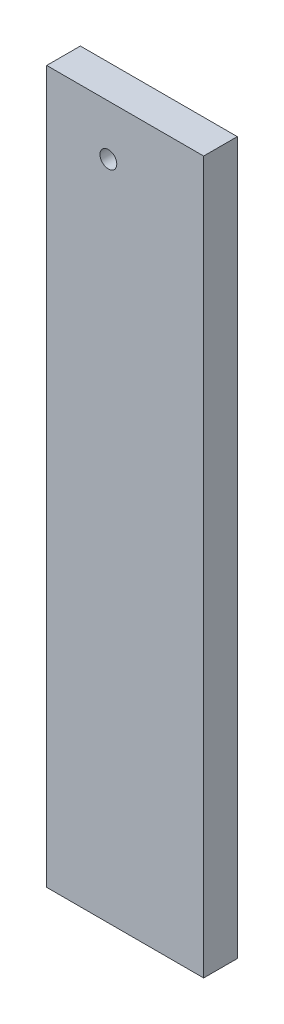
from build123d import *

# Parameters (mm, degrees)
SKETCH1_W               = 88.9
SKETCH1_H               = 403.225
BOSS_EXTRUDE1_DEPTH     = 9.525
SKETCH2_R               = 4.7625
CUT_EXTRUDE1_DEPTH      = 1
CUT_EXTRUDE1_DEPTH_BACK = 20.05


with BuildPart() as part:
    # Sketch1 → Boss-Extrude1 (new body, symmetric)
    with BuildSketch(Plane.XY):
        Rectangle(SKETCH1_W, SKETCH1_H)
    extrude(amount=BOSS_EXTRUDE1_DEPTH, both=True)

    # Sketch2 → Cut-Extrude1 (cut, two sides)
    with BuildSketch(Plane.XY.offset(9.525)) as cut_extrude1_sk:
        with Locations((-9.525, 173.0375)):
            Circle(SKETCH2_R)
    extrude(amount=CUT_EXTRUDE1_DEPTH, mode=Mode.SUBTRACT)
    extrude(cut_extrude1_sk.sketch, amount=-CUT_EXTRUDE1_DEPTH_BACK, mode=Mode.SUBTRACT)


solid = part.part
